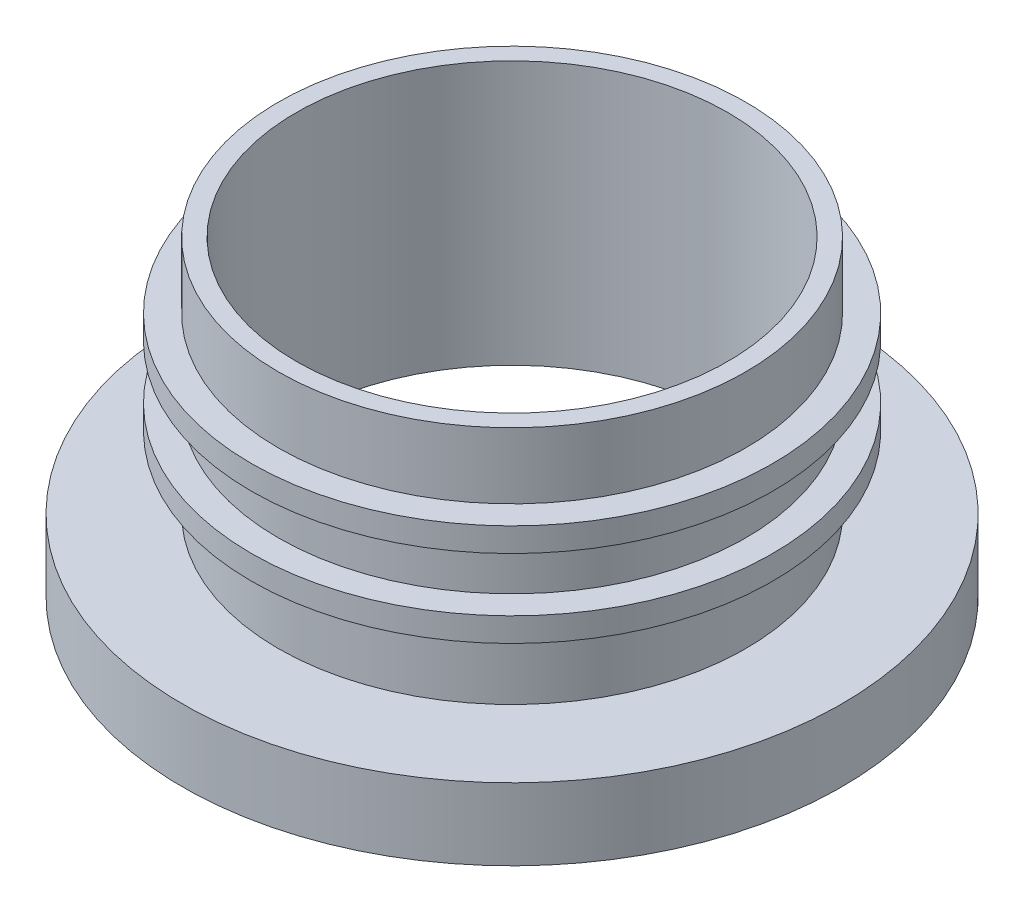
from build123d import *

# Parameters (mm, degrees)
SKETCH_1_R          = 19.5
SKETCH_1_R_2        = 18
EXTRUDE_1_DEPTH     = 20
SKETCH_3_R          = 27.5
EXTRUDE_2_DEPTH     = 2
SKETCH_4_R          = 21.75
EXTRUDE_3_DEPTH     = 2
EXTRUDE_START       = 3
SKETCH_8_R          = 21.75
EXTRUDE_4_DEPTH     = 2
SKETCH_6_R          = 18
CUT_EXTRUDE_1_DEPTH = 35
SKETCH_13_R         = 27.5
SKETCH_13_R_2       = 25
EXTRUDE_6_DEPTH     = 4
SKETCH_13_4_R       = 18
CUT_EXTRUDE_2_DEPTH = 23.5


with BuildPart() as part:
    # 草圖1 → 填料-伸長1 (new body)
    with BuildSketch(Plane(origin=(0, 0, 0), x_dir=(1, 0, 0), z_dir=(0, 1, 0))):
        Circle(SKETCH_1_R)
        Circle(SKETCH_1_R_2, mode=Mode.SUBTRACT)
    extrude(amount=EXTRUDE_1_DEPTH)

    # 草圖3 → 填料-伸長2 (add)
    with BuildSketch(Plane.XZ):
        Circle(SKETCH_3_R)
    extrude(amount=EXTRUDE_2_DEPTH)

    # 草圖4 → 填料-伸長3 (add)
    with BuildSketch(Plane(origin=(0, 8, 0), x_dir=(1, 0, 0), z_dir=(0, 1, 0))):
        Circle(SKETCH_4_R)
    extrude(amount=-EXTRUDE_3_DEPTH)

    # 草圖8 → 填料-伸長4 (add)
    with BuildSketch(Plane(origin=(0, 11.5, 0), x_dir=(1, 0, 0), z_dir=(0, 1, 0)).offset(EXTRUDE_START)):
        Circle(SKETCH_8_R)
    extrude(amount=-EXTRUDE_4_DEPTH)

    # 草圖6 → 除料-伸長1 (cut)
    with BuildSketch(Plane(origin=(0, 0, 0), x_dir=(1, 0, 0), z_dir=(0, 1, 0))):
        Circle(SKETCH_6_R)
    extrude(amount=CUT_EXTRUDE_1_DEPTH, mode=Mode.SUBTRACT)

    # 草圖13 → 填料-伸長6 (add)
    with BuildSketch(Plane.XZ.offset(2)):
        Circle(SKETCH_13_R)
        Circle(SKETCH_13_R_2, mode=Mode.SUBTRACT)
    extrude(amount=EXTRUDE_6_DEPTH)

    # 草圖13<4> → 除料-伸長2 (cut)
    with BuildSketch(Plane.XZ.offset(2)):
        Circle(SKETCH_13_4_R)
    extrude(amount=-CUT_EXTRUDE_2_DEPTH, mode=Mode.SUBTRACT)


solid = part.part
